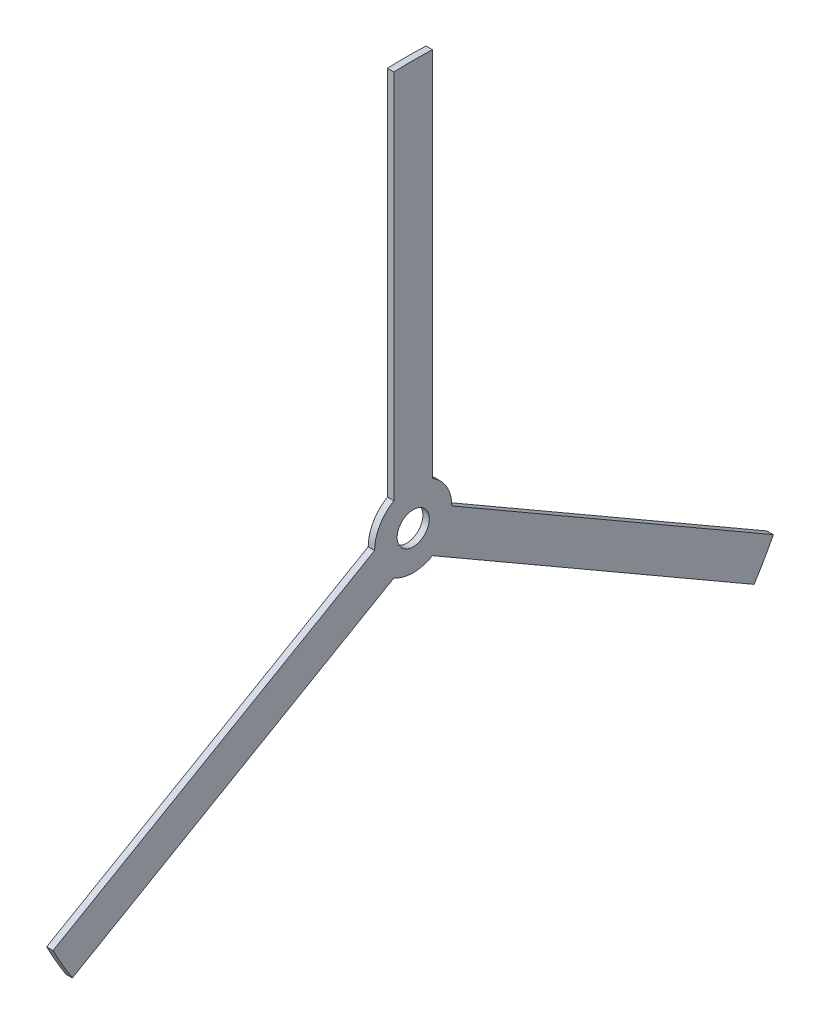
from build123d import *

# Parameters (mm, degrees)
SKETCH_1_R               = 63
SKETCH_1_R_2             = 2.5
EXTRUDE_1_DEPTH          = 1
CUT_EXTRUDE_1_DEPTH      = 1
PATTERN_CIRCULAR_1_COUNT = 3


with BuildPart() as part:
    # 草图1 → 凸台-拉伸1 (new body)
    with BuildSketch(Plane(origin=(0, 0, 0), x_dir=(0, 0, -1), z_dir=(1, 0, 0))):
        Circle(SKETCH_1_R)
        Circle(SKETCH_1_R_2, mode=Mode.SUBTRACT)
    extrude(amount=EXTRUDE_1_DEPTH)

    # 草图2 → 切除-拉伸1 (cut)
    with BuildSketch(Plane.ZY):
        with BuildLine():
            Line((-3, 5.196152423), (-3, 62.92853089))
            ThreePointArc((-3, 62.92853089), (-54.559600438, 31.5), (-55.997706374, -28.866189234))
            Line((-55.997706374, -28.866189234), (-6, 0))
            ThreePointArc((-6, 0), (-5.196152423, 3), (-3, 5.196152423))
        make_face()
    cut_extrude_1 = extrude(amount=-CUT_EXTRUDE_1_DEPTH, mode=Mode.SUBTRACT)

    # 阵列(圆周)1: 切除-拉伸1 ×3 about axis
    pattern_circular_1_axis = Axis((1.05, 0, 0), (-1, 0, 0))
    for i in range(1, PATTERN_CIRCULAR_1_COUNT):
        add(cut_extrude_1.rotate(pattern_circular_1_axis, i * 360 / PATTERN_CIRCULAR_1_COUNT), mode=Mode.SUBTRACT)


solid = part.part
